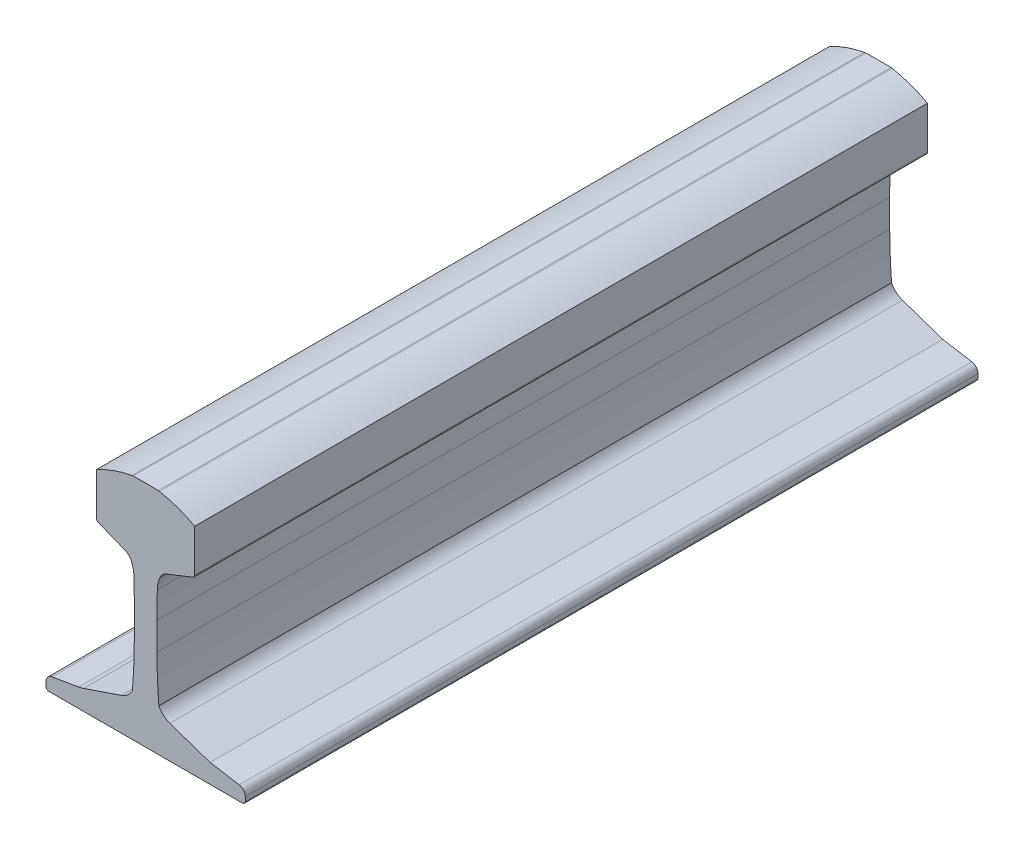
from build123d import *

# Parameters (mm, degrees)
BOSS_EXTRUDE1_DEPTH = 500


with BuildPart() as part:
    # Sketch3 → Boss-Extrude1 (new body)
    with BuildSketch(Plane.XY):
        with BuildLine():
            Line((0, 0), (-66, 0))
            ThreePointArc((-66, 0), (-67.414213562, 0.585786438), (-68, 2))
            Line((-68, 2), (-68, 4.765190248))
            ThreePointArc((-68, 4.765190248), (-66.815034418, 7.997142041), (-63.821795043, 9.697193178))
            Line((-63.821795043, 9.697193178), (-45.627404821, 12.72883365))
            ThreePointArc((-45.627404821, 12.72883365), (-44.016636876, 13.065865401), (-42.439030045, 13.534182026))
            Line((-42.439030045, 13.534182026), (-16.479262031, 22.417915838))
            ThreePointArc((-16.479262031, 22.417915838), (-12.091385863, 24.966143716), (-9.013249079, 29))
            ThreePointArc((-9.013249079, 29), (-8.065943267, 44.487135998), (-7.75, 60))
            Line((-7.75, 60), (-7.75, 79))
            ThreePointArc((-7.75, 79), (-7.803158877, 88.000627905), (-7.962628091, 97))
            ThreePointArc((-7.962628091, 97), (-8.43329292, 101.07664564), (-9.636561641, 105))
            ThreePointArc((-9.636561641, 105), (-11.41229559, 107.653272086), (-14.084201862, 109.400842023))
            Line((-14.084201862, 109.400842023), (-32.238737772, 116.616858833))
            ThreePointArc((-32.238737772, 116.616858833), (-33.154913222, 117.352365228), (-33.5, 118.475424545))
            Line((-33.5, 118.475424545), (-33.5, 147.339300155))
            ThreePointArc((-33.5, 147.339300155), (-21.78437547, 152.590959224), (-9.379525087, 155.900863764))
            ThreePointArc((-9.379525087, 155.900863764), (-9.003111167, 155.954824325), (-8.623684969, 155.980022357))
            ThreePointArc((-8.623684969, 155.980022357), (0, 156.101961392), (8.623684969, 155.980022357))
            ThreePointArc((8.623684969, 155.980022357), (9.003111167, 155.954824325), (9.379525087, 155.900863764))
            ThreePointArc((9.379525087, 155.900863764), (21.78437547, 152.590959224), (33.5, 147.339300155))
            Line((33.5, 147.339300155), (33.5, 118.475424545))
            ThreePointArc((33.5, 118.475424545), (33.154913222, 117.352365228), (32.238737772, 116.616858833))
            Line((32.238737772, 116.616858833), (14.084201862, 109.400842023))
            ThreePointArc((14.084201862, 109.400842023), (11.41229559, 107.653272086), (9.636561641, 105))
            ThreePointArc((9.636561641, 105), (8.43329292, 101.07664564), (7.962628091, 97))
            ThreePointArc((7.962628091, 97), (7.803158877, 88.000627905), (7.75, 79))
            Line((7.75, 79), (7.75, 60))
            ThreePointArc((7.75, 60), (8.065943267, 44.487135998), (9.013249079, 29))
            ThreePointArc((9.013249079, 29), (12.091385863, 24.966143716), (16.479262031, 22.417915838))
            Line((16.479262031, 22.417915838), (44, 12.999999996))
            Line((44, 12.999999996), (63.821795043, 9.697193178))
            ThreePointArc((63.821795043, 9.697193178), (66.815034418, 7.997142041), (68, 4.765190248))
            Line((68, 4.765190248), (68, 2))
            ThreePointArc((68, 2), (67.414213562, 0.585786438), (66, 0))
            Line((66, 0), (0, 0))
        make_face()
    extrude(amount=BOSS_EXTRUDE1_DEPTH)


solid = part.part
